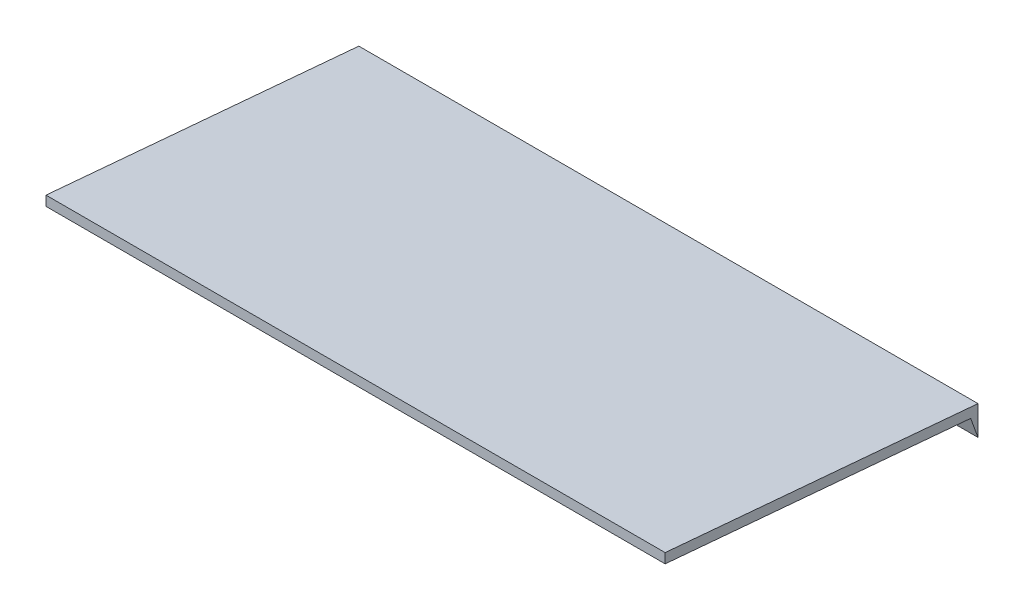
from build123d import *

# Parameters (mm, degrees)
EXTRUDE1_DEPTH = 3.166666667


with BuildPart() as part:
    # Sketch1 → Extrude1 (new body, symmetric)
    with BuildSketch(Plane(origin=(0, 0, 0), x_dir=(0, 0, -1), z_dir=(1, 0, 0))):
        Polygon((0, 0), (3.2, -0.279963723), (3.2, -0.579963723), (3.124811712, -0.3733856), (0, -0.1), align=None)
    extrude(amount=EXTRUDE1_DEPTH, both=True)


solid = part.part
